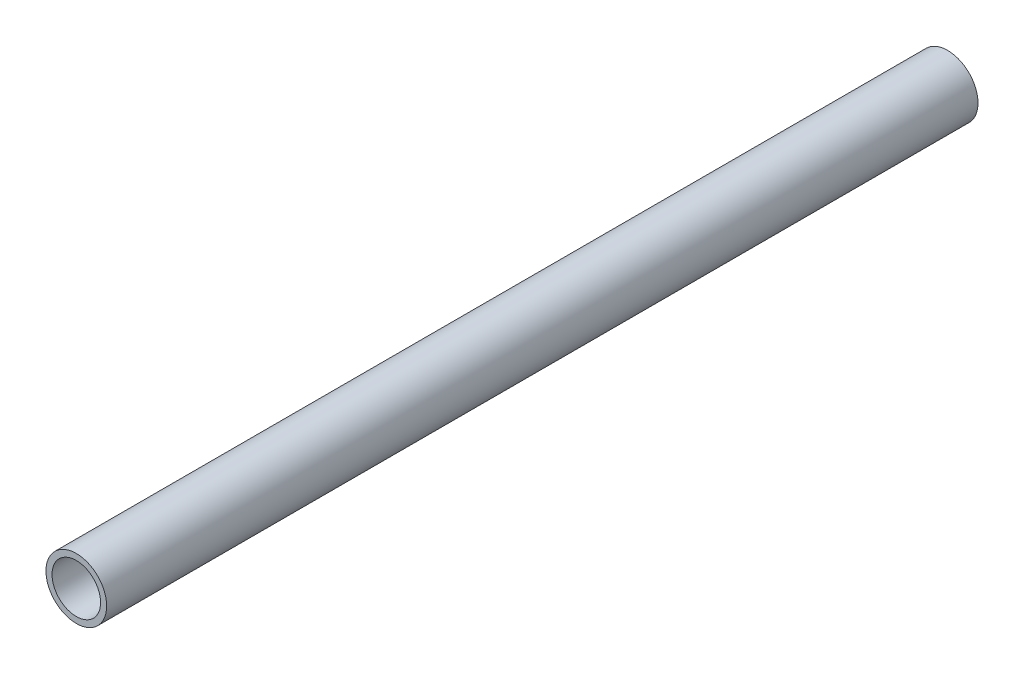
from build123d import *

# Parameters (mm, degrees)
SKETCH2_R           = 5
SKETCH2_R_2         = 4
BOSS_EXTRUDE2_DEPTH = 143.5


with BuildPart() as part:
    # Sketch2 → Boss-Extrude2 (new body)
    with BuildSketch(Plane.XY):
        Circle(SKETCH2_R)
        Circle(SKETCH2_R_2, mode=Mode.SUBTRACT)
    extrude(amount=BOSS_EXTRUDE2_DEPTH)


solid = part.part
